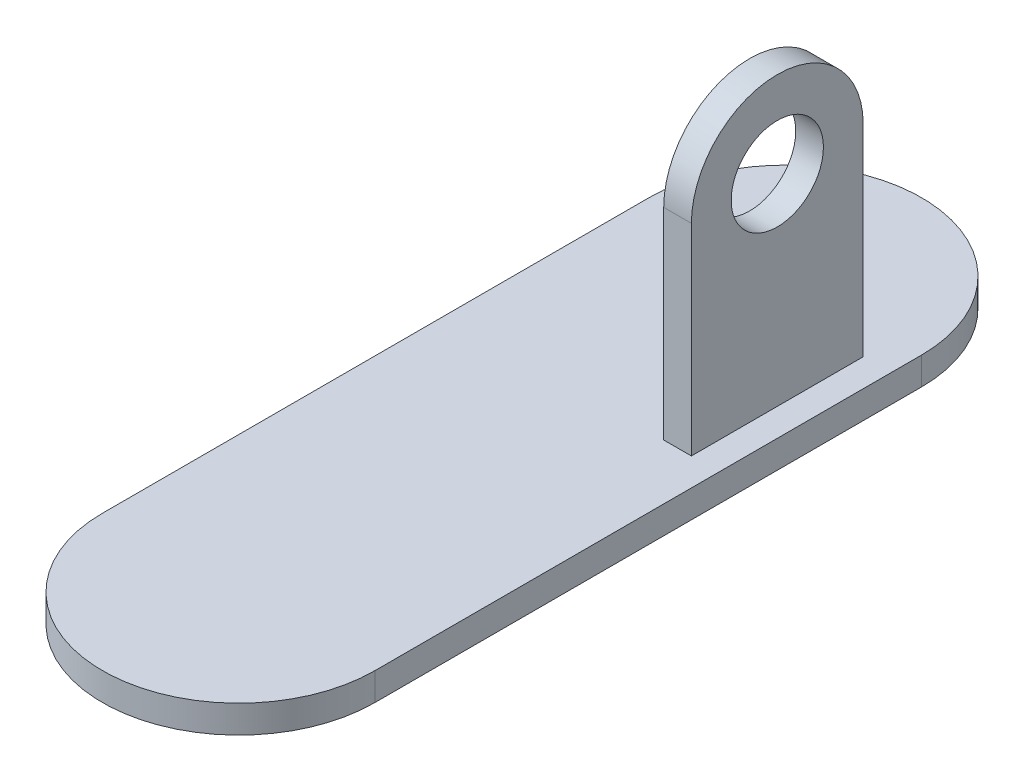
from build123d import *

# Parameters (mm, degrees)
BOSS_EXTRUDE1_DEPTH = 9
SKETCH2_W           = 9
SKETCH2_H           = 55.88
BOSS_EXTRUDE2_DEPTH = 65.53
SKETCH3_R           = 27.94
BOSS_EXTRUDE3_DEPTH = 9
SKETCH4_R           = 15
CUT_EXTRUDE1_DEPTH  = 80.646


with BuildPart() as part:
    # Sketch1 → Boss-Extrude1 (new body)
    with BuildSketch(Plane(origin=(0, 0, 0), x_dir=(1, 0, 0), z_dir=(0, 1, 0))):
        with BuildLine():
            Line((44.323, 88.9), (44.323, -88.9))
            ThreePointArc((44.323, -88.9), (0, -133.223), (-44.323, -88.9))
            Line((-44.323, -88.9), (-44.323, 88.9))
            ThreePointArc((-44.323, 88.9), (0, 133.223), (44.323, 88.9))
        make_face()
    extrude(amount=BOSS_EXTRUDE1_DEPTH)

    # Sketch2 → Boss-Extrude2 (add)
    with BuildSketch(Plane(origin=(0, 9, 0), x_dir=(1, 0, 0), z_dir=(0, 1, 0))):
        with Locations((30.823, 50.96)):
            Rectangle(SKETCH2_W, SKETCH2_H)
    extrude(amount=BOSS_EXTRUDE2_DEPTH)

    # Sketch3 → Boss-Extrude3 (add)
    with BuildSketch(Plane(origin=(35.323, 0, 0), x_dir=(0, 0, -1), z_dir=(1, 0, 0))):
        with Locations((50.96, 74.53)):
            Circle(SKETCH3_R)
    extrude(amount=-BOSS_EXTRUDE3_DEPTH)

    # Sketch4 → Cut-Extrude1 (cut, through all)
    with BuildSketch(Plane(origin=(35.323, 0, 0), x_dir=(0, 0, -1), z_dir=(1, 0, 0))):
        with Locations((50.96, 74.53)):
            Circle(SKETCH4_R)
    extrude(amount=-CUT_EXTRUDE1_DEPTH, mode=Mode.SUBTRACT)


solid = part.part
